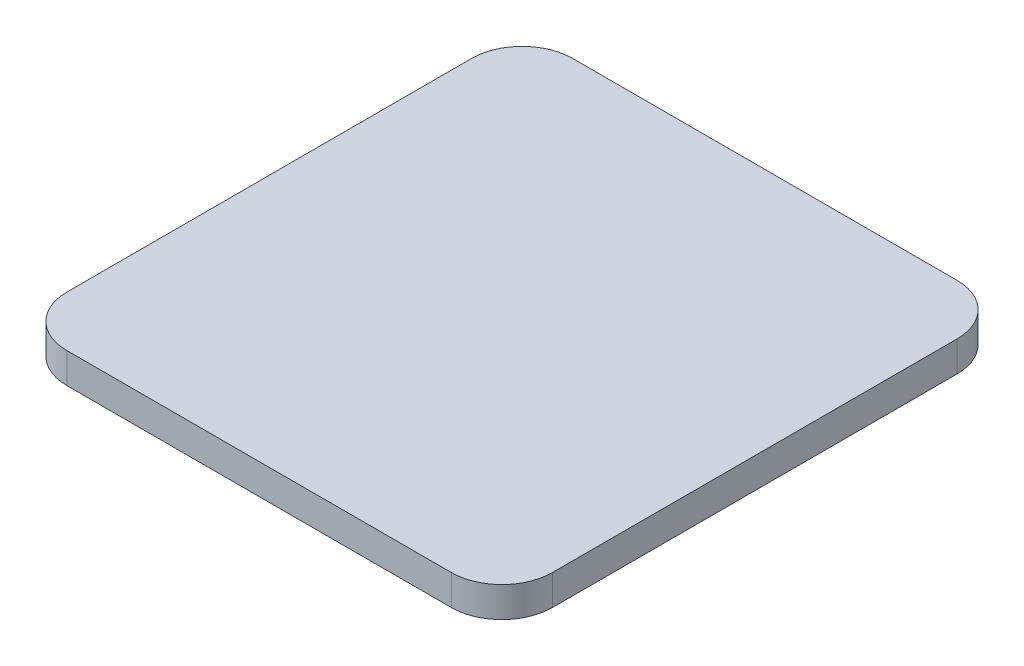
from build123d import *

# Parameters (mm, degrees)
BOSS_EXTRUDE1_DEPTH = 3


with BuildPart() as part:
    # Sketch1 → Boss-Extrude1 (new body)
    with BuildSketch(Plane.XZ.offset(-21.823289438)):
        with BuildLine():
            Line((13.921525611, 28.280531955), (51.921525611, 28.280531955))
            ThreePointArc((51.921525611, 28.280531955), (55.457059517, 29.744998049), (56.921525611, 33.280531955))
            Line((56.921525611, 33.280531955), (56.921525611, 73.280531955))
            ThreePointArc((56.921525611, 73.280531955), (55.457059517, 76.816065861), (51.921525611, 78.280531955))
            Line((51.921525611, 78.280531955), (13.921525611, 78.280531955))
            ThreePointArc((13.921525611, 78.280531955), (10.385991705, 76.816065861), (8.921525611, 73.280531955))
            Line((8.921525611, 73.280531955), (8.921525611, 33.280531955))
            ThreePointArc((8.921525611, 33.280531955), (10.385991705, 29.744998049), (13.921525611, 28.280531955))
        make_face()
    extrude(amount=BOSS_EXTRUDE1_DEPTH)


solid = part.part
